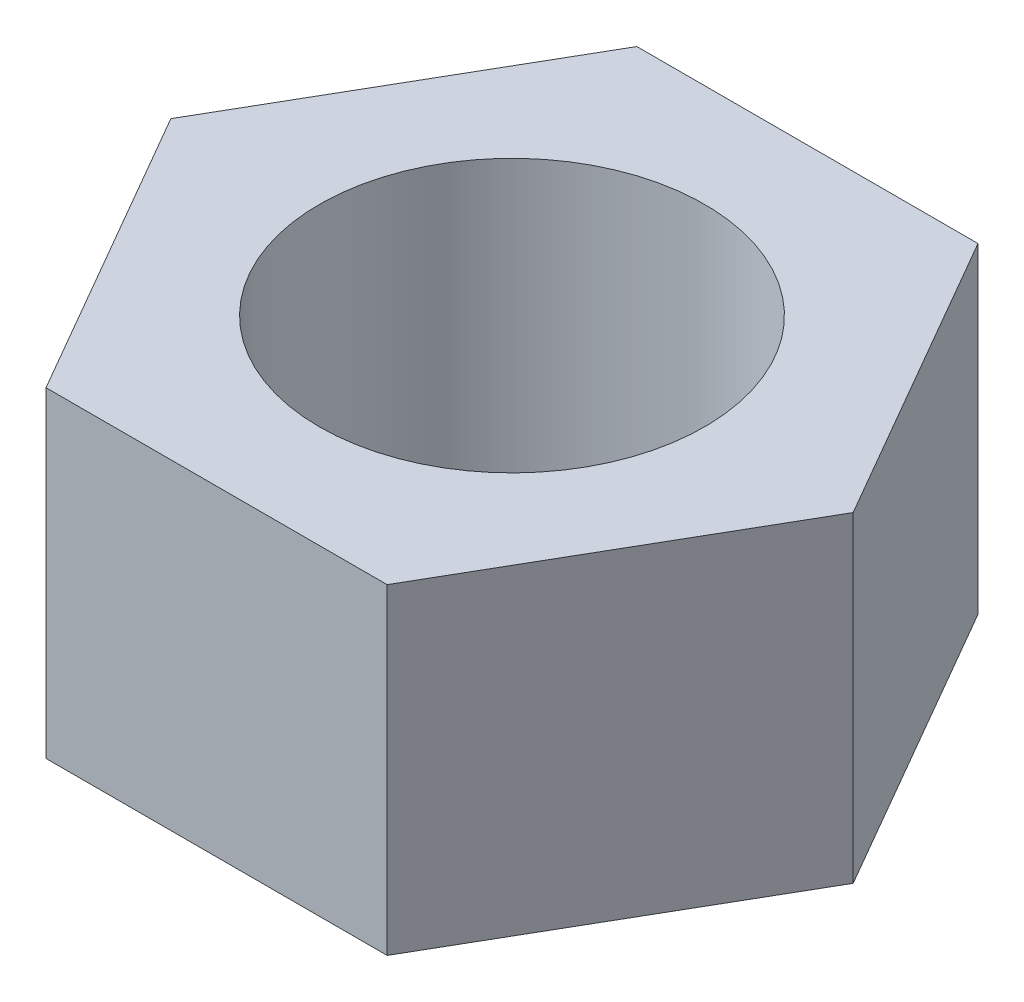
from build123d import *

# Parameters (mm, degrees)
SKETCH_1_R      = 1.5
EXTRUDE_2_DEPTH = 2.5


with BuildPart() as part:
    # 草图1 → 凸台-拉伸2 (new body)
    with BuildSketch(Plane(origin=(0, 0, 0), x_dir=(1, 0, 0), z_dir=(0, 1, 0))):
        Polygon((-1.327905619, 2.3), (-2.655811238, 0), (-1.327905619, -2.3), (1.327905619, -2.3), (2.655811238, 0), (1.327905619, 2.3), align=None)
        Circle(SKETCH_1_R, mode=Mode.SUBTRACT)
    extrude(amount=EXTRUDE_2_DEPTH)


solid = part.part
